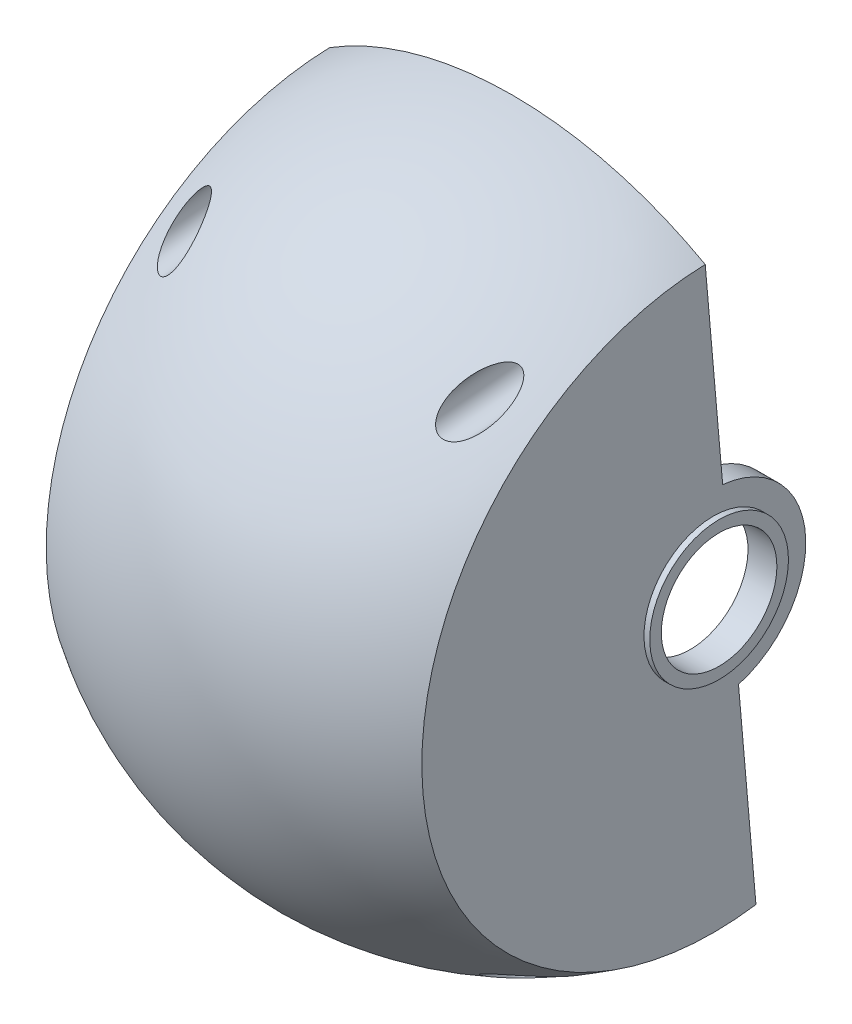
from build123d import *

# Parameters (mm, degrees)
BOSS_EXTRUDE7_REACH             = 140.044
SKETCH13_W                      = 65
SKETCH13_H                      = 55
CUT_EXTRUDE1_REACH              = 108.888
SKETCH3_R                       = 10
SKETCH4_R                       = 12
SKETCH4_R_2                     = 10
BOSS_EXTRUDE2_DEPTH             = 1
CUT_EXTRUDE4_REACH              = 137.688
CUT_EXTRUDE4_END_RADIUS         = 56
SKETCH15_W                      = 59
SKETCH15_H                      = 49
CUT_EXTRUDE5_REACH              = 109.499
SKETCH16_R                      = 7.5
SKETCH18_R                      = 9.5
SKETCH18_R_2                    = 7.5
BOSS_EXTRUDE8_DEPTH             = 10
SKETCH19_R                      = 11.5
SKETCH19_R_2                    = 9.5
BOSS_EXTRUDE9_DEPTH             = 1
CUT_EXTRUDE2_DEPTH              = 95.901264481
CUT_EXTRUDE2_DEPTH_BACK         = 95.901264481
BOSS_EXTRUDE4_REACH             = 96.901
BOSS_EXTRUDE4_END_RADIUS        = 56
SKETCH10_W                      = 4
SKETCH10_H                      = 30
BOSS_EXTRUDE4_DIRECTION_2_DEPTH = 7.5
CUT_EXTRUDE3_REACH              = 101
SKETCH11_R                      = 2
SKETCH11_W                      = 40.5
SKETCH11_H                      = 20.75
BOSS_EXTRUDE10_REACH            = 98.981
SKETCH20_R                      = 5
M3_CLEARANCE_HOLE1_D            = 3.2
SKETCH21_R                      = 3.25
CUT_EXTRUDE6_DEPTH              = 61


with BuildPart() as part:
    # Sketch1 → Revolve1 (revolve)
    with BuildSketch(Plane.XY):
        with BuildLine():
            Line((-32.5, 50.435602505), (-32.5, 0))
            Line((-32.5, 0), (-28.5, 0))
            Line((-28.5, 0), (-28.5, 48.205290166))
            ThreePointArc((-28.5, 48.205290166), (0, 56), (28.5, 48.205290166))
            Line((28.5, 48.205290166), (28.5, 0))
            Line((28.5, 0), (32.5, 0))
            Line((32.5, 0), (32.5, 50.435602505))
            ThreePointArc((32.5, 50.435602505), (0, 60), (-32.5, 50.435602505))
        make_face()
    revolve(axis=Axis((-32.5, 0, 0), (1, 0, 0)))

    # Sketch13 → Boss-Extrude7 (add, up to next)
    with BuildSketch(Plane(origin=(0, 0, -60), x_dir=(-1, 0, 0), z_dir=(0, 0, -1)), mode=Mode.PRIVATE) as boss_extrude7_sk1:
        Rectangle(SKETCH13_W, SKETCH13_H)
    boss_extrude7_tool1 = extrude(boss_extrude7_sk1.sketch, amount=-BOSS_EXTRUDE7_REACH, mode=Mode.PRIVATE) - part.part
    add(boss_extrude7_tool1.solids().sort_by_distance((0, 0, -60))[0])

    # Sketch3 → Cut-Extrude1 (cut, up to next)
    with BuildSketch(Plane(origin=(32.5, 0, 0), x_dir=(0, 0, -1), z_dir=(1, 0, 0)), mode=Mode.PRIVATE) as cut_extrude1_sk1:
        with Locations(Location((0, 0, 0), (0, 0, 90))):
            Circle(SKETCH3_R)
    cut_extrude1_tool1 = extrude(cut_extrude1_sk1.sketch, amount=-CUT_EXTRUDE1_REACH, mode=Mode.PRIVATE) & part.part
    add(cut_extrude1_tool1.solids().sort_by_distance((32.5, 0, 0))[0], mode=Mode.SUBTRACT)

    # Sketch4 → Boss-Extrude2 (add)
    with BuildSketch(Plane(origin=(32.5, 0, 0), x_dir=(0, 0, -1), z_dir=(1, 0, 0))):
        with Locations(Location((0, 0, 0), (0, 0, 90))):
            Circle(SKETCH4_R)
        with Locations(Location((0, 0, 0), (0, 0, 90))):
            Circle(SKETCH4_R_2, mode=Mode.SUBTRACT)
    extrude(amount=BOSS_EXTRUDE2_DEPTH)

    # Cut-Extrude4: up to this sphere (the profile starts outside it)
    cut_extrude4_end = Location((0, 0, 0)) * Sphere(CUT_EXTRUDE4_END_RADIUS, mode=Mode.PRIVATE)
    # Sketch15 → Cut-Extrude4 (cut, up to the surface)
    with BuildSketch(Plane(origin=(0, 0, -57), x_dir=(-1, 0, 0), z_dir=(0, 0, -1)), mode=Mode.PRIVATE) as cut_extrude4_sk1:
        Rectangle(SKETCH15_W, SKETCH15_H)
    cut_extrude4_tool1 = extrude(cut_extrude4_sk1.sketch, amount=-CUT_EXTRUDE4_REACH, mode=Mode.PRIVATE) - cut_extrude4_end
    add(cut_extrude4_tool1.solids().sort_by_distance((0, 0, -57))[0], mode=Mode.SUBTRACT)

    # Sketch16 → Cut-Extrude5 (cut, up to next)
    with BuildSketch(Plane.ZY.offset(32.5), mode=Mode.PRIVATE) as cut_extrude5_sk1:
        with Locations(Location((0, 0, 0), (0, 0, 270))):
            Circle(SKETCH16_R)
    cut_extrude5_tool1 = extrude(cut_extrude5_sk1.sketch, amount=-CUT_EXTRUDE5_REACH, mode=Mode.PRIVATE) & part.part
    add(cut_extrude5_tool1.solids().sort_by_distance((-32.5, 0, 0))[0], mode=Mode.SUBTRACT)

    # Sketch18 → Boss-Extrude8 (add)
    with BuildSketch(Plane.ZY.offset(32.5)):
        with Locations(Location((0, 0, 0), (0, 0, 270))):
            Circle(SKETCH18_R)
        with Locations(Location((0, 0, 0), (0, 0, 270))):
            Circle(SKETCH18_R_2, mode=Mode.SUBTRACT)
    extrude(amount=BOSS_EXTRUDE8_DEPTH)

    # Sketch19 → Boss-Extrude9 (add)
    with BuildSketch(Plane.ZY.offset(32.5)):
        with Locations(Location((0, 0, 0), (0, 0, 270))):
            Circle(SKETCH19_R)
        with Locations(Location((0, 0, 0), (0, 0, 270))):
            Circle(SKETCH19_R_2, mode=Mode.SUBTRACT)
    extrude(amount=BOSS_EXTRUDE9_DEPTH)

    # Sketch5 → Cut-Extrude2 (cut, two sides)
    with BuildSketch(Plane(origin=(0, 0, 0), x_dir=(0, 0, -1), z_dir=(1, 0, 0))) as cut_extrude2_sk:
        with BuildLine():
            Line((4.358344111, -15.394961403), (8.260779324, -60))
            Line((8.260779324, -60), (60, -60))
            Line((60, -60), (60, 60))
            Line((60, 60), (-2.237860299, 60))
            Line((-2.237860299, 60), (1.618824078, 15.91789586))
            ThreePointArc((1.618824078, 15.91789586), (15.939115169, 1.394491884), (4.358344111, -15.394961403))
        make_face()
    extrude(amount=CUT_EXTRUDE2_DEPTH, mode=Mode.SUBTRACT)
    extrude(cut_extrude2_sk.sketch, amount=-CUT_EXTRUDE2_DEPTH_BACK, mode=Mode.SUBTRACT)

    # Boss-Extrude4: up to this sphere (the profile starts inside it)
    boss_extrude4_end = Location((0, 0, 0)) * Sphere(BOSS_EXTRUDE4_END_RADIUS, mode=Mode.PRIVATE)
    # Sketch10 → Boss-Extrude4 (add, up to the surface)
    with BuildSketch(Plane.XY, mode=Mode.PRIVATE) as boss_extrude4_sk1:
        with Locations((10.5, -17.6)):
            Rectangle(SKETCH10_W, SKETCH10_H)
    boss_extrude4_tool1 = extrude(boss_extrude4_sk1.sketch, amount=BOSS_EXTRUDE4_REACH, mode=Mode.PRIVATE) & boss_extrude4_end
    add(boss_extrude4_tool1.solids().sort_by_distance((10.5, -17.6, 0))[0])

    # Sketch10 → Boss-Extrude4 direction 2 (add)
    with BuildSketch(Plane.XY):
        with Locations((10.5, -17.6)):
            Rectangle(SKETCH10_W, SKETCH10_H)
    extrude(amount=-BOSS_EXTRUDE4_DIRECTION_2_DEPTH)

    # Sketch11 → Cut-Extrude3 (cut, up to next)
    with BuildSketch(Plane.ZY.offset(-8.5), mode=Mode.PRIVATE) as cut_extrude3_sk1:
        with Locations(Location((46.1, -17.35, 0), (0, 0, 270))):
            Circle(SKETCH11_R)
    cut_extrude3_tool1 = extrude(cut_extrude3_sk1.sketch, amount=-CUT_EXTRUDE3_REACH, mode=Mode.PRIVATE) & part.part
    # Sketch11 → Cut-Extrude3 (cut, up to next)
    with BuildSketch(Plane.ZY.offset(-8.5), mode=Mode.PRIVATE) as cut_extrude3_sk2:
        with Locations(Location((46.1, -7.6, 0), (0, 0, 270))):
            Circle(SKETCH11_R)
    cut_extrude3_tool2 = extrude(cut_extrude3_sk2.sketch, amount=-CUT_EXTRUDE3_REACH, mode=Mode.PRIVATE) & part.part
    # Sketch11 → Cut-Extrude3 (cut, up to next)
    with BuildSketch(Plane.ZY.offset(-8.5), mode=Mode.PRIVATE) as cut_extrude3_sk3:
        with Locations(Location((-2.5, -7.6, 0), (0, 0, 270))):
            Circle(SKETCH11_R)
    cut_extrude3_tool3 = extrude(cut_extrude3_sk3.sketch, amount=-CUT_EXTRUDE3_REACH, mode=Mode.PRIVATE) & part.part
    # Sketch11 → Cut-Extrude3 (cut, up to next)
    with BuildSketch(Plane.ZY.offset(-8.5), mode=Mode.PRIVATE) as cut_extrude3_sk4:
        with Locations(Location((-2.5, -17.35, 0), (0, 0, 270))):
            Circle(SKETCH11_R)
    cut_extrude3_tool4 = extrude(cut_extrude3_sk4.sketch, amount=-CUT_EXTRUDE3_REACH, mode=Mode.PRIVATE) & part.part
    # Sketch11 → Cut-Extrude3 (cut, up to next)
    with BuildSketch(Plane.ZY.offset(-8.5), mode=Mode.PRIVATE) as cut_extrude3_sk5:
        with Locations((21.8, -12.975)):
            Rectangle(SKETCH11_W, SKETCH11_H)
    cut_extrude3_tool5 = extrude(cut_extrude3_sk5.sketch, amount=-CUT_EXTRUDE3_REACH, mode=Mode.PRIVATE) & part.part
    add(cut_extrude3_tool1.solids().sort_by_distance((8.5, -17.35, 46.1))[0], mode=Mode.SUBTRACT)
    add(cut_extrude3_tool2.solids().sort_by_distance((8.5, -7.6, 46.1))[0], mode=Mode.SUBTRACT)
    add(cut_extrude3_tool3.solids().sort_by_distance((8.5, -7.6, -2.5))[0], mode=Mode.SUBTRACT)
    add(cut_extrude3_tool4.solids().sort_by_distance((8.5, -17.35, -2.5))[0], mode=Mode.SUBTRACT)
    add(cut_extrude3_tool5.solids().sort_by_distance((8.5, -12.975, 21.8))[0], mode=Mode.SUBTRACT)

    # Sketch20 → Boss-Extrude10 (add, up to next)
    with BuildSketch(Plane(origin=(0, 0.261467228, -2.988584094), x_dir=(-1, 0, 0), z_dir=(0, 0.08715574274766202, -0.9961946980917452)), mode=Mode.PRIVATE) as boss_extrude10_sk1:
        with Locations((-25.5, 45.111848852)):
            Circle(SKETCH20_R)
    boss_extrude10_tool1 = extrude(boss_extrude10_sk1.sketch, amount=-BOSS_EXTRUDE10_REACH, mode=Mode.PRIVATE) - part.part
    # Sketch20 → Boss-Extrude10 (add, up to next)
    with BuildSketch(Plane(origin=(0, 0.261467228, -2.988584094), x_dir=(-1, 0, 0), z_dir=(0, 0.08715574274766202, -0.9961946980917452)), mode=Mode.PRIVATE) as boss_extrude10_sk2:
        with Locations((25.5, 45.111848852)):
            Circle(SKETCH20_R)
    boss_extrude10_tool2 = extrude(boss_extrude10_sk2.sketch, amount=-BOSS_EXTRUDE10_REACH, mode=Mode.PRIVATE) - part.part
    # Sketch20 → Boss-Extrude10 (add, up to next)
    with BuildSketch(Plane(origin=(0, 0.261467228, -2.988584094), x_dir=(-1, 0, 0), z_dir=(0, 0.08715574274766202, -0.9961946980917452)), mode=Mode.PRIVATE) as boss_extrude10_sk3:
        with Locations((25.5, -45.111848852)):
            Circle(SKETCH20_R)
    boss_extrude10_tool3 = extrude(boss_extrude10_sk3.sketch, amount=-BOSS_EXTRUDE10_REACH, mode=Mode.PRIVATE) - part.part
    # Sketch20 → Boss-Extrude10 (add, up to next)
    with BuildSketch(Plane(origin=(0, 0.261467228, -2.988584094), x_dir=(-1, 0, 0), z_dir=(0, 0.08715574274766202, -0.9961946980917452)), mode=Mode.PRIVATE) as boss_extrude10_sk4:
        with Locations((-25.5, -45.111848852)):
            Circle(SKETCH20_R)
    boss_extrude10_tool4 = extrude(boss_extrude10_sk4.sketch, amount=-BOSS_EXTRUDE10_REACH, mode=Mode.PRIVATE) - part.part
    add(boss_extrude10_tool1.solids().sort_by_distance((25.5, 45.201652, 0.943173))[0])
    add(boss_extrude10_tool2.solids().sort_by_distance((-25.5, 45.201652, 0.943173))[0])
    add(boss_extrude10_tool3.solids().sort_by_distance((-25.5, -44.678717, -6.920341))[0])
    add(boss_extrude10_tool4.solids().sort_by_distance((25.5, -44.678717, -6.920341))[0])

    # M3 Clearance Hole1 (through all)
    with Locations(Plane(origin=(0, -5.229344565, 59.771681886), x_dir=(1, 0, 0), z_dir=(0, -0.08715574274766202, 0.9961946980917453))):
        with Locations((-25.5, 45.111848852), (25.5, 45.111848852), (-25.5, -45.111848852), (25.5, -45.111848852)):
            Hole(M3_CLEARANCE_HOLE1_D / 2)

    # Sketch21 → Cut-Extrude6 (cut)
    with BuildSketch(Plane(origin=(0, -5.229344565, 59.771681886), x_dir=(1, 0, 0), z_dir=(0, -0.08715574274766202, 0.9961946980917453))):
        with Locations(Location((-25.5, 45.111848852, 0), (0, 0, 270))):
            Circle(SKETCH21_R)
        with Locations(Location((25.5, 45.111848852, 0), (0, 0, 270))):
            Circle(SKETCH21_R)
        with Locations(Location((-25.5, -45.111848852, 0), (0, 0, 270))):
            Circle(SKETCH21_R)
        with Locations(Location((25.5, -45.111848852, 0), (0, 0, 270))):
            Circle(SKETCH21_R)
    extrude(amount=-CUT_EXTRUDE6_DEPTH, mode=Mode.SUBTRACT)


solid = part.part
